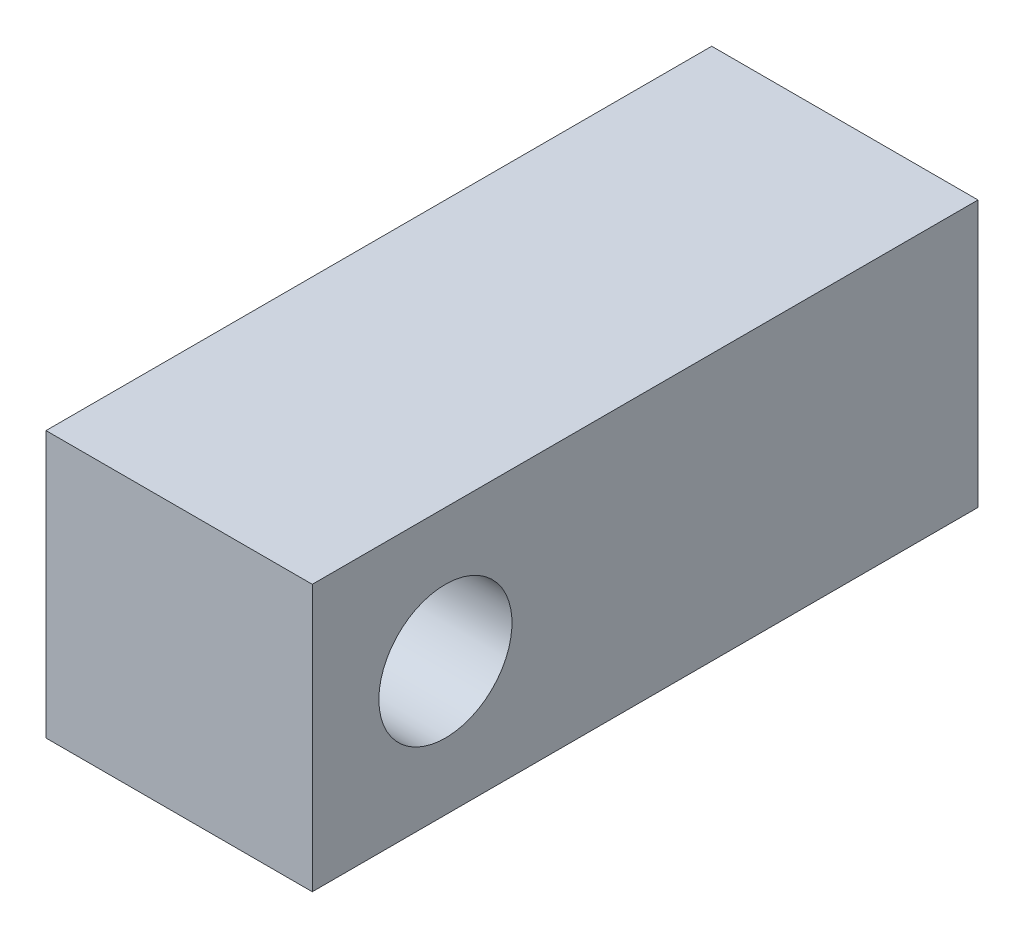
from build123d import *

# Parameters (mm, degrees)
SKETCH1_W           = 25.4
SKETCH1_H           = 25.4
BOSS_EXTRUDE1_DEPTH = 63.5
SKETCH2_R           = 6.35
CUT_EXTRUDE1_DEPTH  = 26.4


with BuildPart() as part:
    # Sketch1 → Boss-Extrude1 (new body)
    with BuildSketch(Plane.XY):
        with Locations((-17.064491321, 20.342163666)):
            Rectangle(SKETCH1_W, SKETCH1_H)
    extrude(amount=BOSS_EXTRUDE1_DEPTH)

    # Sketch2 → Cut-Extrude1 (cut, through all)
    with BuildSketch(Plane.ZY.offset(29.764491321)):
        with Locations((50.8, 20.342163666)):
            Circle(SKETCH2_R)
    extrude(amount=-CUT_EXTRUDE1_DEPTH, mode=Mode.SUBTRACT)


solid = part.part
